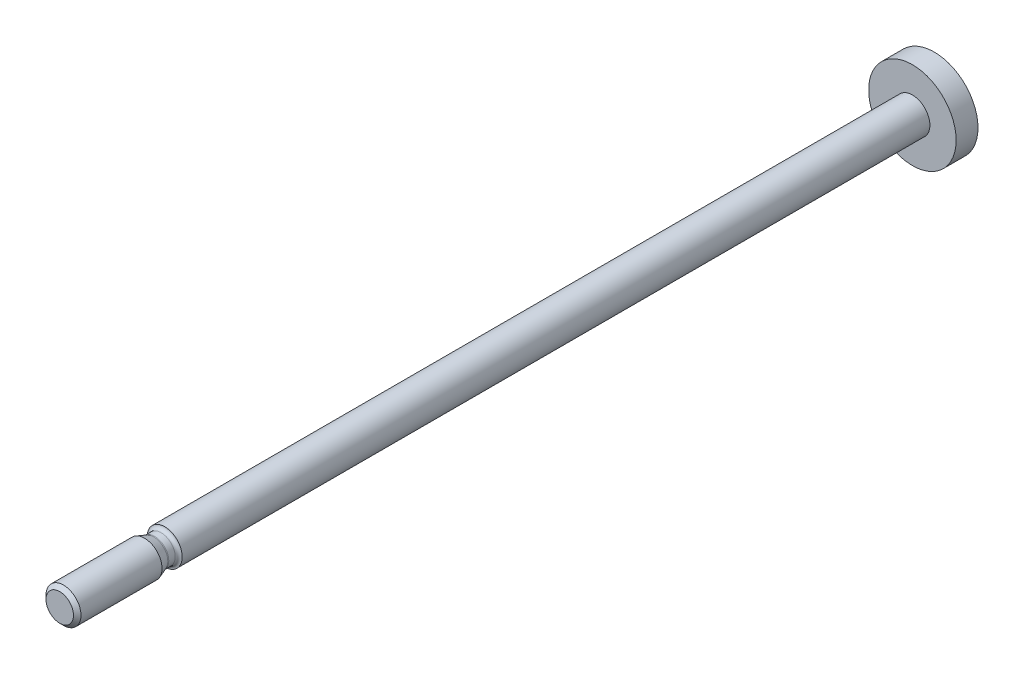
from build123d import *


with BuildPart() as part:
    # Sketch1 → Revolve1 (revolve)
    with BuildSketch(Plane(origin=(0, 0, 0), x_dir=(0, 0, -1), z_dir=(1, 0, 0))):
        Polygon((-4, 0), (-4, 2), (81.5, 2), (81.5, 5), (84, 5), (84, 0), align=None)
    revolve(axis=Axis((0, 0, -84), (0, 0, 1)))

    # Sketch2 → Revolve2 (revolve)
    with BuildSketch(Plane(origin=(0, 0, 0), x_dir=(0, 0, -1), z_dir=(1, 0, 0))):
        with BuildLine():
            Line((-16, 0), (-16, 1.5705))
            Line((-16, 1.5705), (-15.5705, 2))
            Line((-15.5705, 2), (-6.298990968, 2))
            Line((-6.298990968, 2), (-5.266277265, 1.624122952))
            ThreePointArc((-5.266277265, 1.624122952), (-5.198928479, 1.606076899), (-5.129469208, 1.6))
            Line((-5.129469208, 1.6), (-4.4, 1.6))
            ThreePointArc((-4.4, 1.6), (-4.117157288, 1.717157288), (-4, 2))
            Line((-4, 2), (-3, 2))
            Line((-3, 2), (-3, 0))
            Line((-3, 0), (-16, 0))
        make_face()
    revolve(axis=Axis((0, 0, 3), (0, 0, 1)))


solid = part.part
